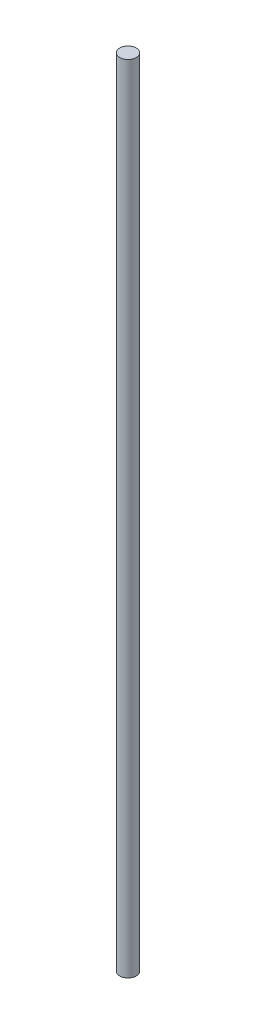
from build123d import *

# Parameters (mm, degrees)
SKETCH1_R           = 4
BOSS_EXTRUDE1_DEPTH = 385


with BuildPart() as part:
    # Sketch1 → Boss-Extrude1 (new body)
    with BuildSketch(Plane(origin=(0, 0, 0), x_dir=(1, 0, 0), z_dir=(0, 1, 0))):
        Circle(SKETCH1_R)
    extrude(amount=BOSS_EXTRUDE1_DEPTH)


solid = part.part
